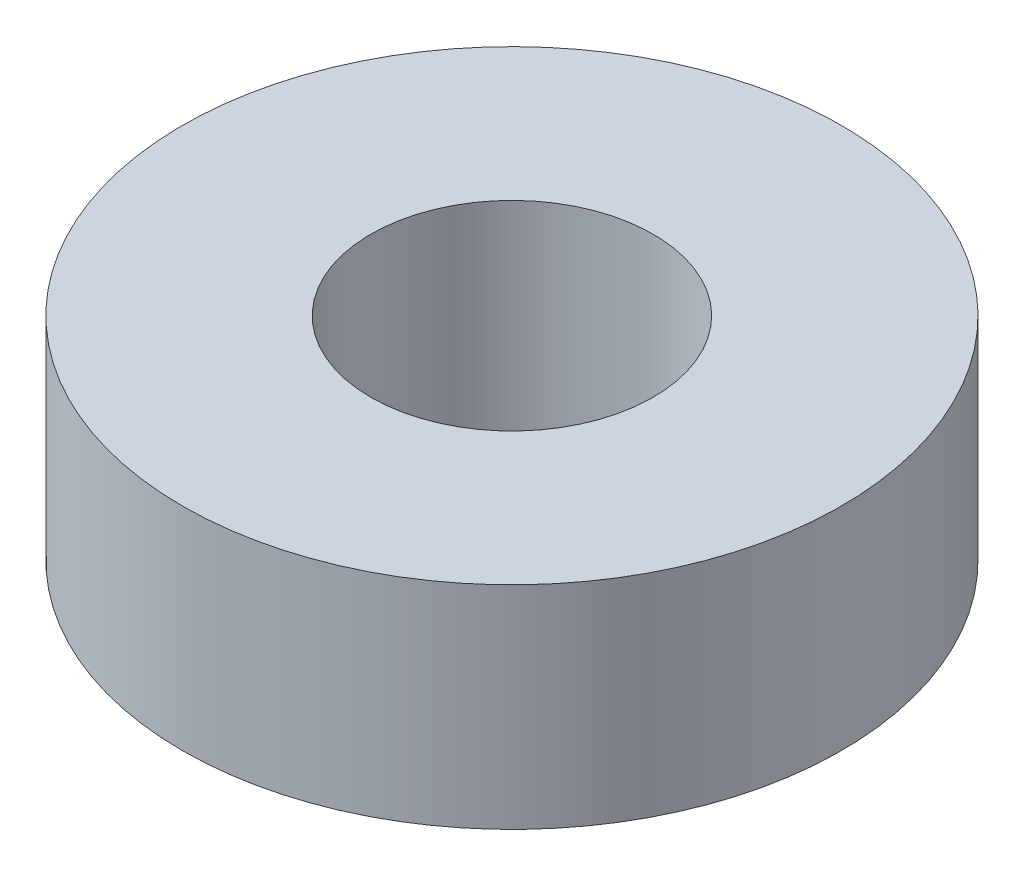
from build123d import *

# Parameters (mm, degrees)
SKETCH1_R           = 11.1125
SKETCH1_R_2         = 4.7625
BOSS_EXTRUDE1_DEPTH = 3.571875


with BuildPart() as part:
    # Sketch1 → Boss-Extrude1 (new body, symmetric)
    with BuildSketch(Plane(origin=(0, 0, 0), x_dir=(1, 0, 0), z_dir=(0, 1, 0))):
        Circle(SKETCH1_R)
        Circle(SKETCH1_R_2, mode=Mode.SUBTRACT)
    extrude(amount=BOSS_EXTRUDE1_DEPTH, both=True)


solid = part.part
